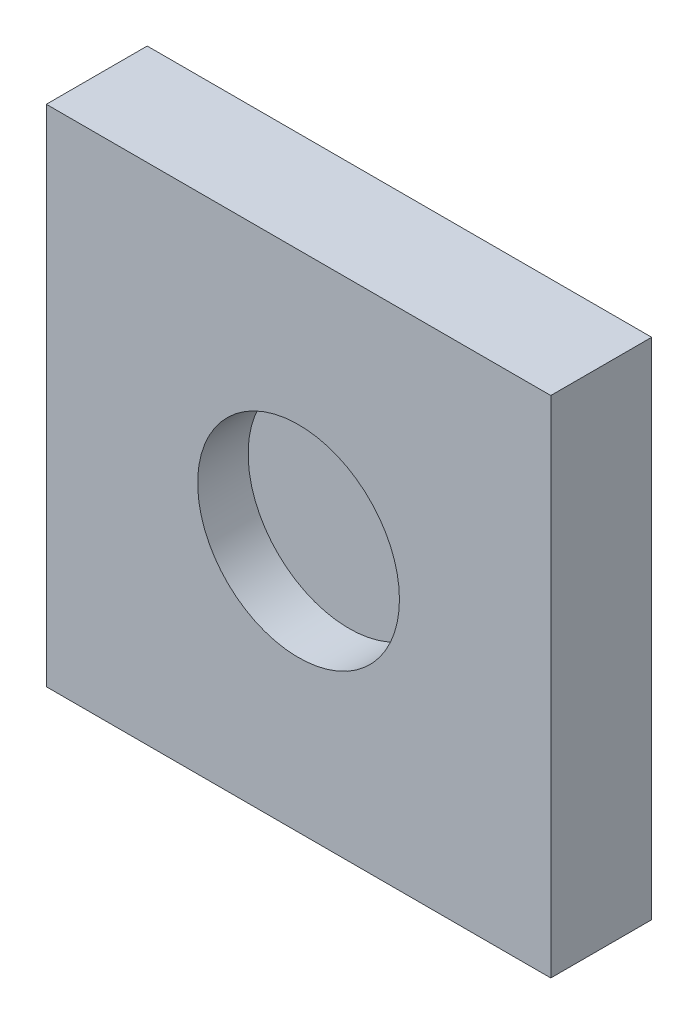
from build123d import *

# Parameters (mm, degrees)
SKETCH2_W           = 100
SKETCH2_H           = 100
BOSS_EXTRUDE1_DEPTH = 20
SKETCH3_R           = 20
CUT_EXTRUDE1_DEPTH  = 10


with BuildPart() as part:
    # Sketch2 → Boss-Extrude1 (new body)
    with BuildSketch(Plane.XY):
        Rectangle(SKETCH2_W, SKETCH2_H)
    extrude(amount=BOSS_EXTRUDE1_DEPTH)

    # Sketch3 → Cut-Extrude1 (cut)
    with BuildSketch(Plane.XY.offset(20)):
        Circle(SKETCH3_R)
    extrude(amount=-CUT_EXTRUDE1_DEPTH, mode=Mode.SUBTRACT)


solid = part.part
